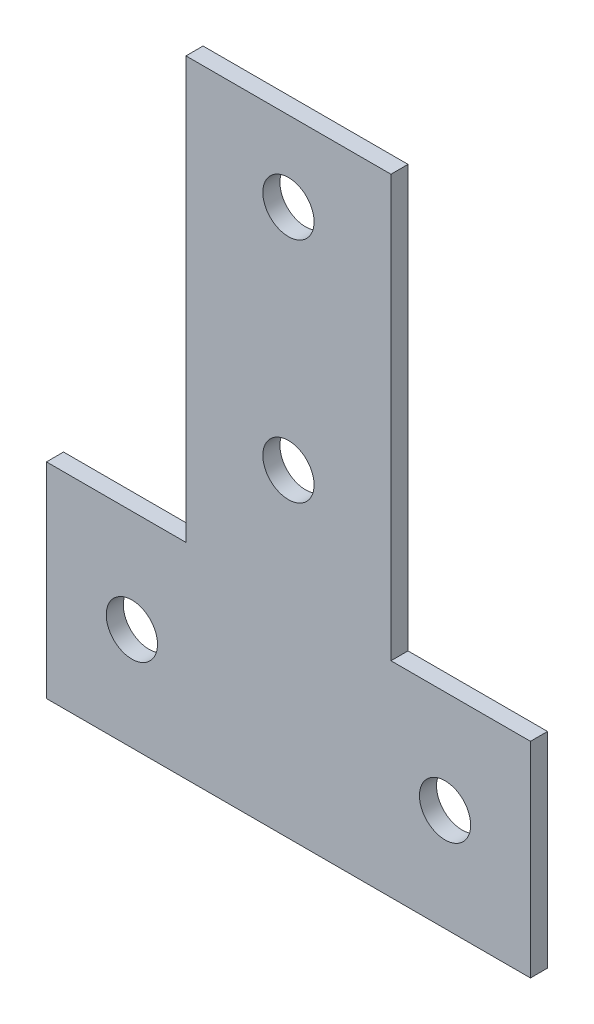
from build123d import *

# Parameters (mm, degrees)
SKETCH_1_R      = 4.5
EXTRUDE_1_DEPTH = 3


with BuildPart() as part:
    # Эскиз1 → Бобышка-Вытянуть1 (new body)
    with BuildSketch(Plane.XY):
        Polygon((-42.5, 0), (42.5, 0), (42.5, 36), (18, 36), (18, 110), (-18, 110), (-18, 36), (-42.5, 36), align=None)
        with Locations((0, 96)):
            Circle(SKETCH_1_R, mode=Mode.SUBTRACT)
        with Locations((0, 56)):
            Circle(SKETCH_1_R, mode=Mode.SUBTRACT)
        with Locations((-27.5, 18)):
            Circle(SKETCH_1_R, mode=Mode.SUBTRACT)
        with Locations((27.5, 18)):
            Circle(SKETCH_1_R, mode=Mode.SUBTRACT)
    extrude(amount=EXTRUDE_1_DEPTH)


solid = part.part
